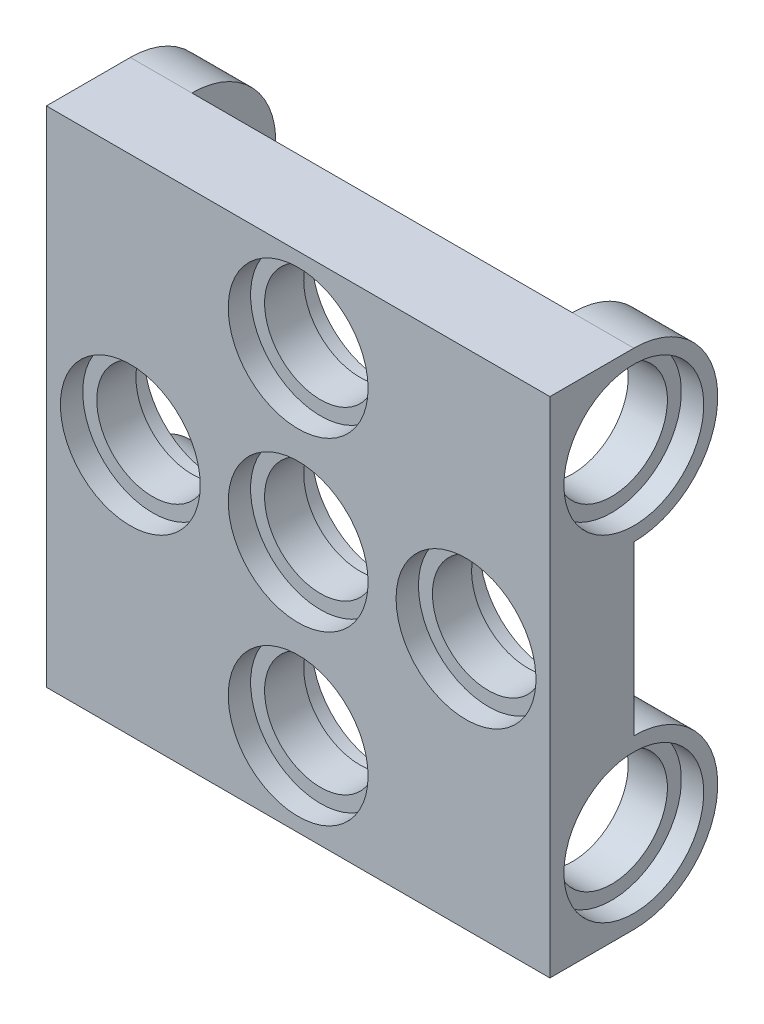
from build123d import *

# Parameters (mm, degrees)
SKETCH1_W           = 9
SKETCH1_H           = 9
BOSS_EXTRUDE1_DEPTH = 3
HOLE1_D             = 4
HOLE1_CBORE_D       = 5
HOLE1_CBORE_DEPTH   = 0.8
BOSS_EXTRUDE3_DEPTH = 2.2
HOLE2_D             = 4
HOLE2_DEPTH         = 2.2
HOLE2_CBORE_D       = 5
HOLE2_CBORE_DEPTH   = 0.8
SKETCH7_R           = 2.5
CUT_EXTRUDE1_DEPTH  = 0.8
SKETCH8_R           = 2.5
CUT_EXTRUDE2_DEPTH  = 0.8


with BuildPart() as part:
    # Sketch1 → Boss-Extrude1 (new body)
    with BuildSketch(Plane.XY):
        with Locations((-4.5, 4.5)):
            Rectangle(SKETCH1_W, SKETCH1_H)
    extrude(amount=BOSS_EXTRUDE1_DEPTH)

    # Hole1 (through all)
    with Locations(Plane.XY.offset(3)):
        with Locations((0, 0), (-6, 0), (0, 6)):
            CounterBoreHole(HOLE1_D / 2, HOLE1_CBORE_D / 2, HOLE1_CBORE_DEPTH)

    # Sketch4 → Boss-Extrude3 (add)
    with BuildSketch(Plane.ZY.offset(9)):
        with BuildLine():
            Line((0, 9), (0, 3))
            ThreePointArc((0, 3), (-3, 6), (0, 9))
        make_face()
    extrude(amount=-BOSS_EXTRUDE3_DEPTH)

    # Hole2
    with Locations(Plane.ZY.offset(9)):
        with Locations((0, 6)):
            CounterBoreHole(HOLE2_D / 2, HOLE2_CBORE_D / 2, HOLE2_CBORE_DEPTH, depth=HOLE2_DEPTH)

    # Sketch7 → Cut-Extrude1 (cut)
    with BuildSketch(Plane(origin=(0, 0, 0), x_dir=(-1, 0, 0), z_dir=(0, 0, -1))):
        with Locations((0, 6)):
            Circle(SKETCH7_R)
        Circle(SKETCH7_R)
        with Locations((6, 0)):
            Circle(SKETCH7_R)
    extrude(amount=-CUT_EXTRUDE1_DEPTH, mode=Mode.SUBTRACT)

    # Sketch8 → Cut-Extrude2 (cut)
    with BuildSketch(Plane(origin=(-6.8, 0, 0), x_dir=(0, 0, -1), z_dir=(1, 0, 0))):
        with Locations((0, 6)):
            Circle(SKETCH8_R)
    extrude(amount=CUT_EXTRUDE2_DEPTH, mode=Mode.SUBTRACT)

    # Mirror1: part across plane


with BuildPart() as part_1:
    add(part.part)
    add(part.part.mirror(Plane(origin=(0, 0, 0), x_dir=(0, 0, 1), z_dir=(1, 0, 0))))

    # Mirror2: part across plane


with BuildPart() as part_2:
    add(part_1.part)
    add(part_1.part.mirror(Plane.ZX))


solid = part_2.part
